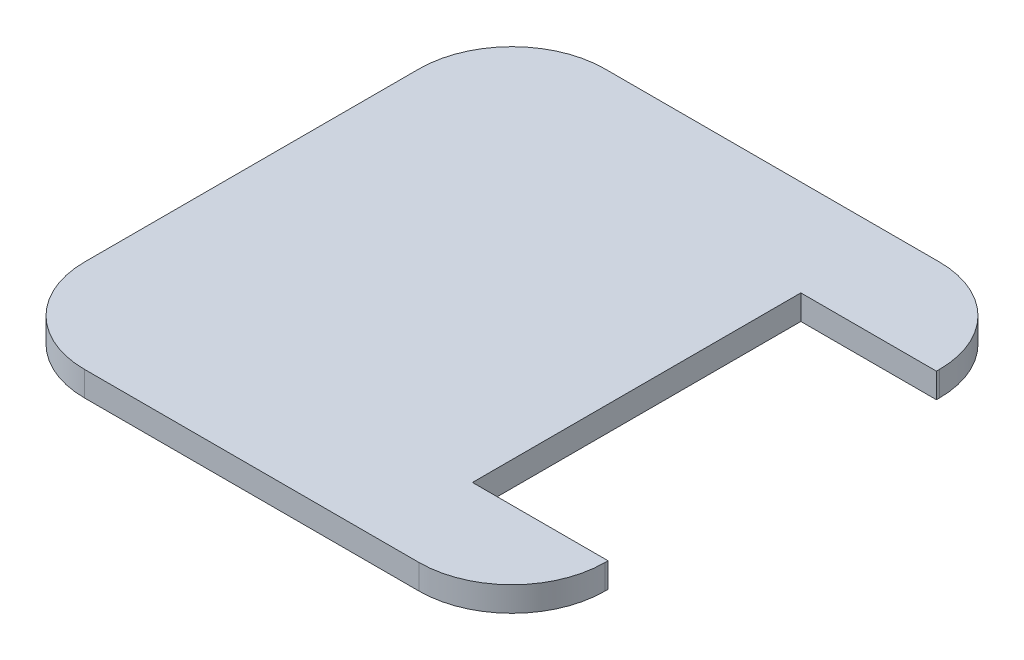
from build123d import *

# Parameters (mm, degrees)
BOSS_EXTRUDE1_DEPTH = 4
SKETCH4_W           = 21.88
SKETCH4_H           = 53
CUT_EXTRUDE1_DEPTH  = 4


with BuildPart() as part:
    # Layer1 → Boss-Extrude1 (new body)
    with BuildSketch(Plane(origin=(0, 0, 0), x_dir=(1, 0, 0), z_dir=(0, 1, 0))):
        with BuildLine():
            Line((27, 42), (11.25, 42))
            Line((11.25, 42), (-27, 42))
            ThreePointArc((-27, 42), (-37.606601718, 37.606601718), (-42, 27))
            Line((-42, 27), (-42, 21.5))
            Line((-42, 21.5), (-42, -21.5))
            Line((-42, -21.5), (-42, -27))
            ThreePointArc((-42, -27), (-37.606601718, -37.606601718), (-27, -42))
            Line((-27, -42), (11.25, -42))
            Line((11.25, -42), (27, -42))
            ThreePointArc((27, -42), (37.606601718, -37.606601718), (42, -27))
            Line((42, -27), (42, 27))
            ThreePointArc((42, 27), (37.606601718, 37.606601718), (27, 42))
        make_face()
    extrude(amount=BOSS_EXTRUDE1_DEPTH)

    # Sketch4 → Cut-Extrude1 (cut)
    with BuildSketch(Plane(origin=(0, 4, 0), x_dir=(1, 0, 0), z_dir=(0, 1, 0))):
        with Locations((31.06, 0)):
            Rectangle(SKETCH4_W, SKETCH4_H)
    extrude(amount=-CUT_EXTRUDE1_DEPTH, mode=Mode.SUBTRACT)


solid = part.part
